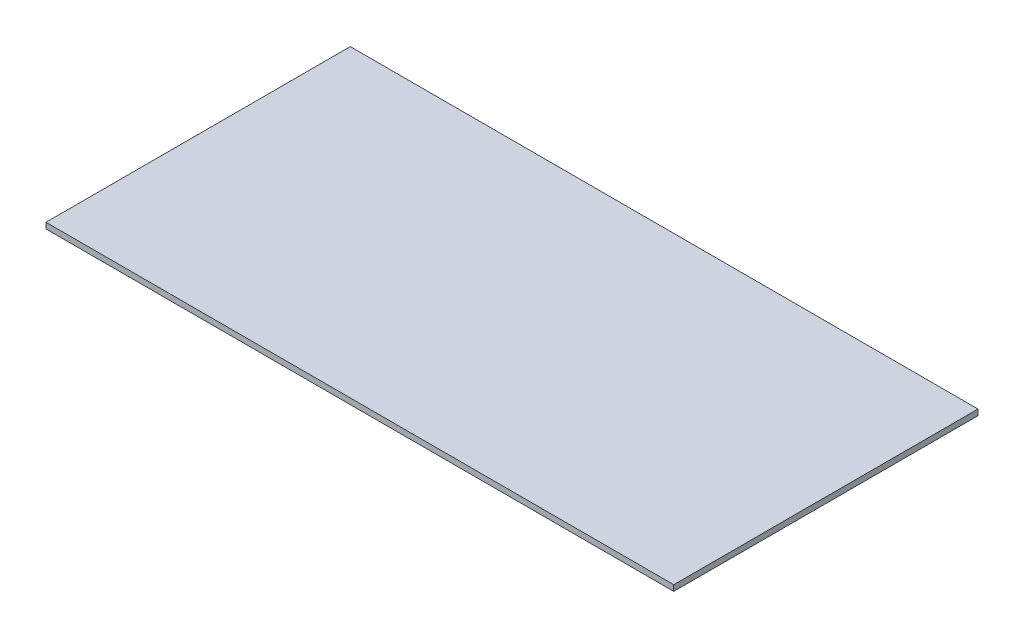
from build123d import *

# Parameters (mm, degrees)
SKETCH1_W           = 131.01574
SKETCH1_H           = 63.5
BOSS_EXTRUDE1_DEPTH = 1.21412


with BuildPart() as part:
    # Sketch1 → Boss-Extrude1 (new body)
    with BuildSketch(Plane(origin=(0, 0, 0), x_dir=(1, 0, 0), z_dir=(0, 1, 0))):
        Rectangle(SKETCH1_W, SKETCH1_H)
    extrude(amount=BOSS_EXTRUDE1_DEPTH)


solid = part.part
